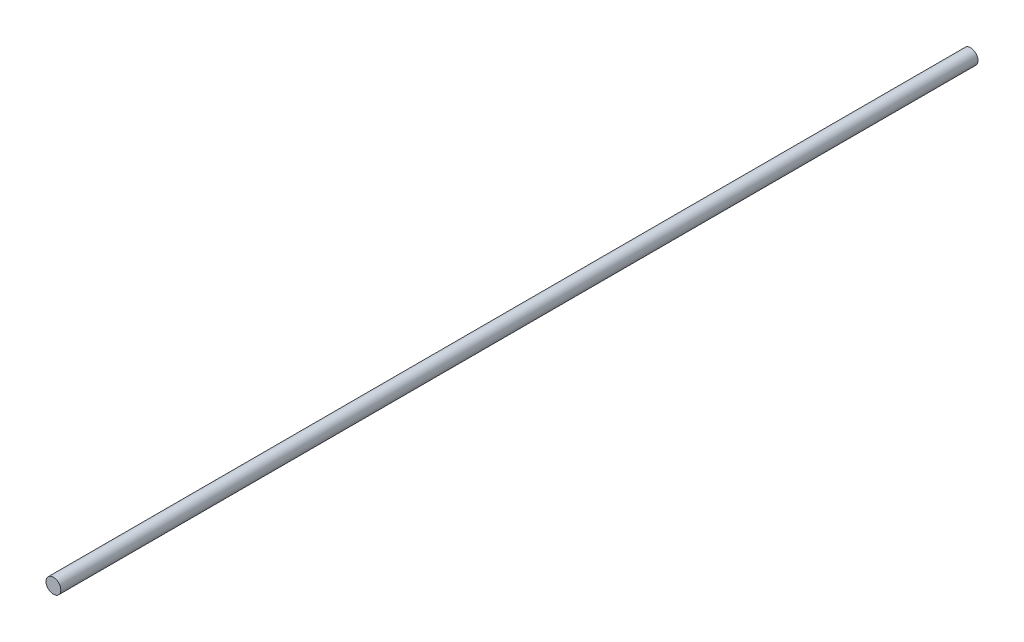
from build123d import *

# Parameters (mm, degrees)
SKETCH1_R           = 2.5
BOSS_EXTRUDE1_DEPTH = 310


with BuildPart() as part:
    # Sketch1 → Boss-Extrude1 (new body)
    with BuildSketch(Plane.XY):
        Circle(SKETCH1_R)
    extrude(amount=BOSS_EXTRUDE1_DEPTH)


solid = part.part
